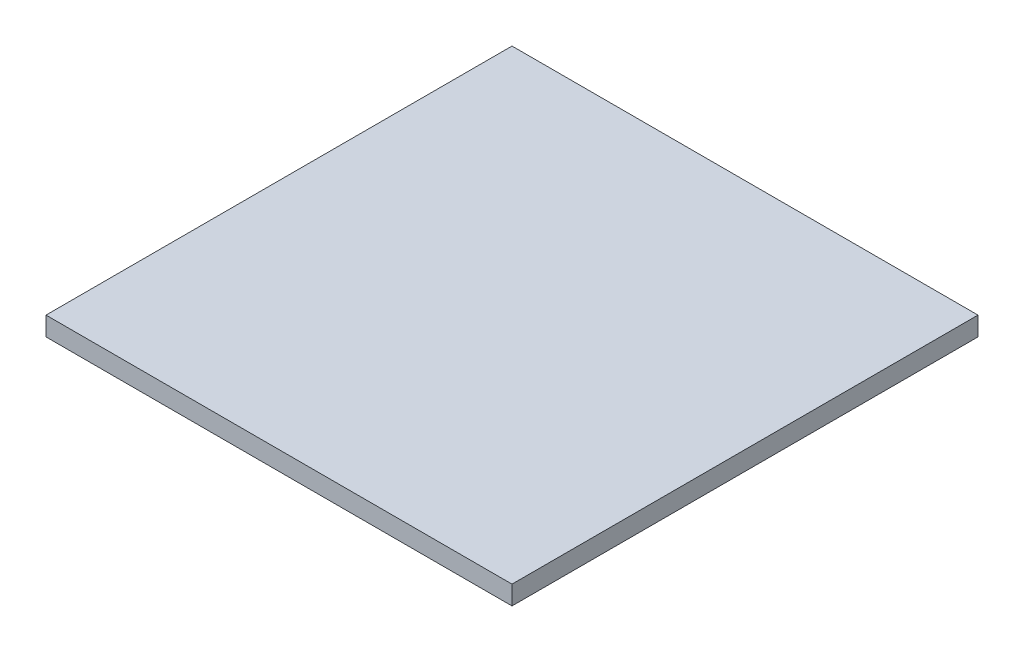
from build123d import *

# Parameters (mm, degrees)
SKETCH_1_W      = 50
SKETCH_1_H      = 50
EXTRUDE_1_DEPTH = 2.03


with BuildPart() as part:
    # 草图1 → 凸台-拉伸1 (new body)
    with BuildSketch(Plane(origin=(0, 0, 0), x_dir=(1, 0, 0), z_dir=(0, 1, 0))):
        Rectangle(SKETCH_1_W, SKETCH_1_H)
    extrude(amount=EXTRUDE_1_DEPTH)


solid = part.part
